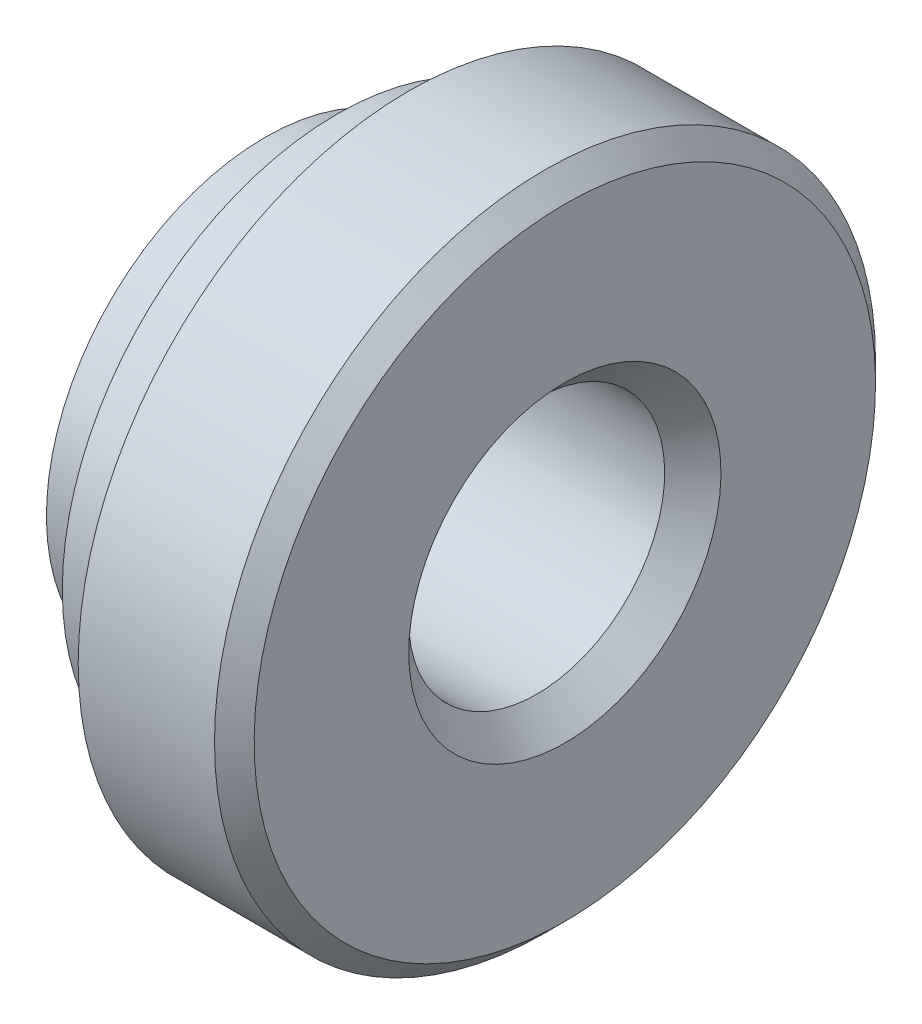
from build123d import *


with BuildPart() as part:
    # Sketch1 → Revolve1 (revolve)
    with BuildSketch(Plane.XY):
        Polygon((0.69, 2.065), (0.318461538, 2.1), (0, 2.1), (0, 1.5), (0.2705, 1.2295), (2.6095, 1.2295), (2.88, 1.5), (2.88, 2.9845), (2.6895, 3.175), (1.38, 3.175), (1.38, 2.6375), (0.69, 2.6375), align=None)
    revolve(axis=Axis((0, 0, 0), (1, 0, 0)))


solid = part.part
